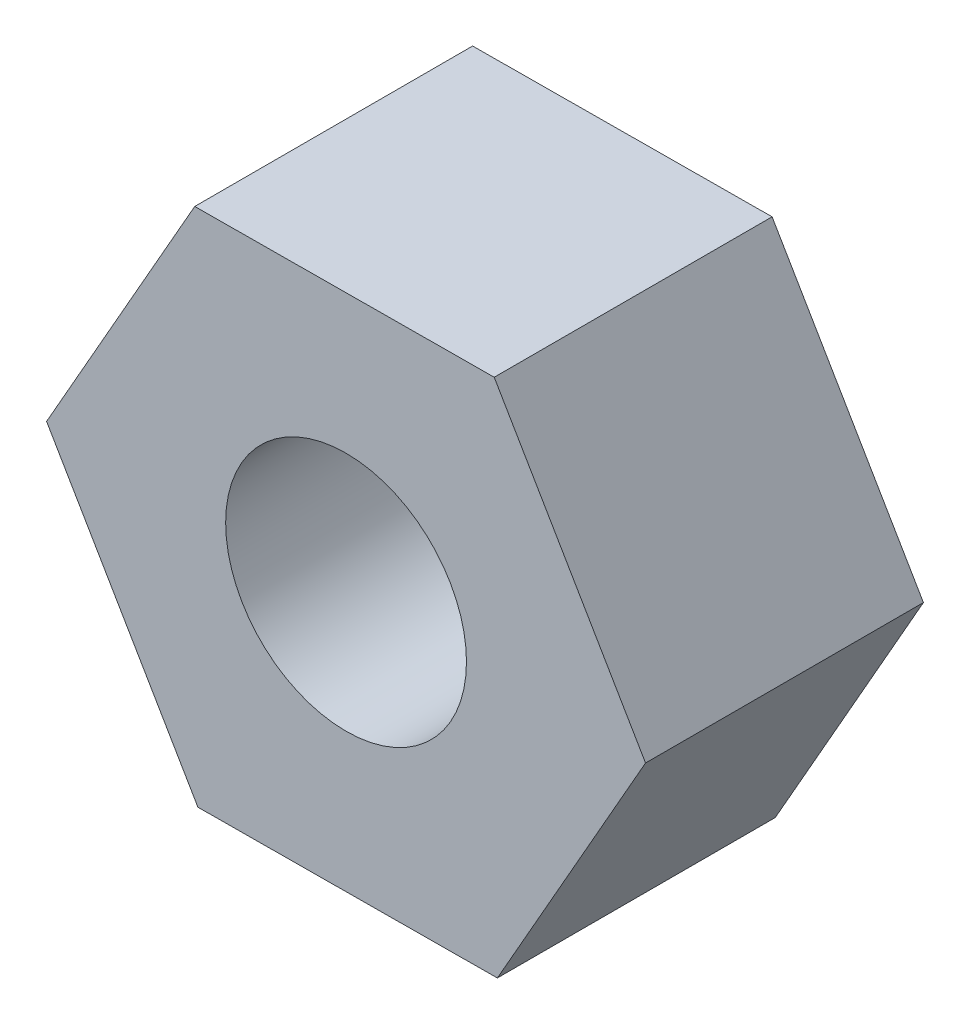
from build123d import *

# Parameters (mm, degrees)
IZIM1_R                     = 6.5
Y_KSEKLIK_EKSTR_ZYON1_DEPTH = 15


with BuildPart() as part:
    # Çizim1 → Yükseklik-Ekstrüzyon1 (new body)
    with BuildSketch(Plane.XY):
        Polygon((8.167965901, -13.950543587), (16.165508093, 0.098394173), (7.997542193, 14.048937761), (-8.167965901, 13.950543587), (-16.165508093, -0.098394173), (-7.997542193, -14.048937761), align=None)
        Circle(IZIM1_R, mode=Mode.SUBTRACT)
    extrude(amount=Y_KSEKLIK_EKSTR_ZYON1_DEPTH)


solid = part.part
